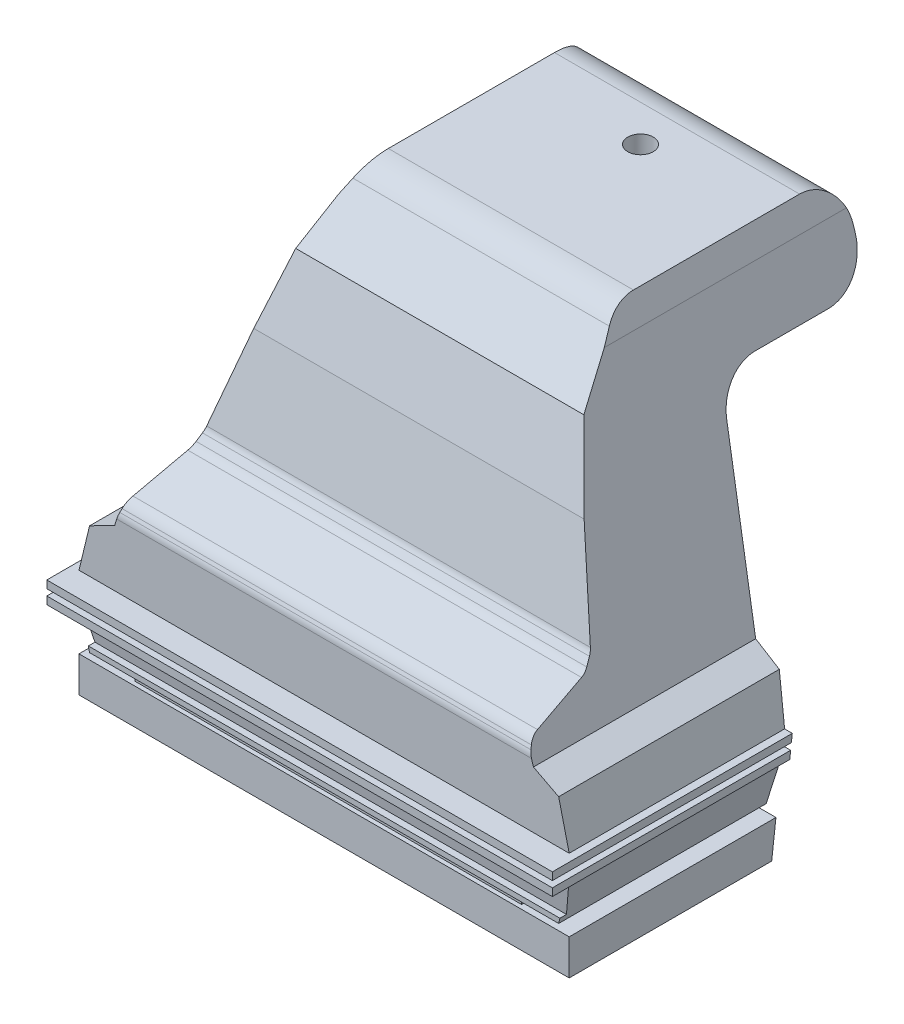
from build123d import *

# Parameters (mm, degrees)
BOSS_EXTRUDE2_DEPTH   = 80
CUT_EXTRUDE6_DEPTH    = 80
FILLET4_R             = 8
FILLET6_R             = 8
BOSS_EXTRUDE3_DEPTH   = 5
CUT_EXTRUDE7_DEPTH    = 53
SKETCH8_W             = 0.862104353
SKETCH8_H             = 1.284661266
CUT_EXTRUDE8_DEPTH    = 53
SKETCH9_R             = 2.6
CUT_EXTRUDE9_DEPTH    = 53
CHAMFER1_SIZE         = 2
CHAMFER1_SIZE2        = 0.352653961
CHAMFER2_SIZE         = 2
CHAMFER2_SIZE2        = 1.125418904
CHAMFER2_PART_2_SIZE  = 2
CHAMFER2_PART_2_SIZE2 = 1.486326178
CHAMFER2_PART_3_SIZE  = 2
CHAMFER2_PART_3_SIZE2 = 12.979996821
FILLET7_R             = 3


with BuildPart() as part:
    # Sketch4 → Boss-Extrude2 (new body)
    with BuildSketch(Plane.XY):
        Polygon((0, 90), (25, 90), (27.110033345, 84.90483075), (42.705570979, 33.625818377), (47.850101428, 30.956311994), (50, 22.038522927), (51.568309777, 22.038522927), (51.568309777, 20.486613591), (50, 20.486613591), (50, 19.211830923), (51.568309777, 19.211830923), (51.568309777, 17.666105021), (50, 17.666105021), (47.850101428, 8.556688769), (39.441409504, 8.556688769), (39.441409504, 7.272027503), (50, 7.272027503), (50, 0), (0, 0), align=None)
    extrude(amount=BOSS_EXTRUDE2_DEPTH)

    # Sketch5 → Cut-Extrude6 (cut)
    with BuildSketch(Plane.ZY):
        Polygon((80, 90), (45.569058945, 90), (57.70788513, 75.886568849), (65.410192712, 42.801872405), (80, 37.57441702), align=None)
        Polygon((30, 72.649548533), (0, 72.649548533), (0, 0), (38.690390773, 0), align=None)
    extrude(amount=-CUT_EXTRUDE6_DEPTH, mode=Mode.SUBTRACT)

    # Fillet4
    fillet4_edges = [part.edges().sort_by_distance(p)[0] for p in [
        (15.418622329, 72.649548533, 0),
        (15.418622329, 72.649548533, 30),
    ]]
    fillet(fillet4_edges, radius=FILLET4_R)

    # Fillet6
    fillet6_edges = [part.edges().sort_by_distance(p)[0] for p in [
        (12.5, 90, 0),
        (12.5, 90, 45.569058945),
    ]]
    fillet(fillet6_edges, radius=FILLET6_R)

    # Sketch6 → Boss-Extrude3 (add)
    with BuildSketch(Plane.XY.offset(80)):
        Polygon((51.568309777, 22.038522927), (50, 22.038522927), (0, 22.038522927), (0, 20.486613591), (50, 20.486613591), (51.568309777, 20.486613591), align=None)
        Polygon((50, 19.211830923), (0, 19.211830923), (0, 17.666105021), (50, 17.666105021), (51.568309777, 17.666105021), (51.568309777, 19.211830923), align=None)
    extrude(amount=BOSS_EXTRUDE3_DEPTH)

    # Sketch7 → Cut-Extrude7 (cut)
    with BuildSketch(Plane.ZY):
        Polygon((80, 17.666105021), (78.657986015, 9.613389648), (80, 9.613389648), align=None)
    extrude(amount=-CUT_EXTRUDE7_DEPTH, mode=Mode.SUBTRACT)

    # Sketch8 → Cut-Extrude8 (cut)
    with BuildSketch(Plane(origin=(39.441409504, 0, 0), x_dir=(0, 0, -1), z_dir=(1, 0, 0))):
        with Locations((-79.568947823, 7.914358136)):
            Rectangle(SKETCH8_W, SKETCH8_H)
    extrude(amount=-CUT_EXTRUDE8_DEPTH, mode=Mode.SUBTRACT)

    # Sketch9 → Cut-Extrude9 (cut)
    with BuildSketch(Plane.XZ.offset(-72.649548533)):
        with Locations((0, 15.44996627)):
            Circle(SKETCH9_R)
    extrude(amount=-CUT_EXTRUDE9_DEPTH, mode=Mode.SUBTRACT)

    # Chamfer1
    chamfer1_edges = [part.edges().sort_by_distance(p)[0] for p in [
        (2.6, 72.649548533, 15.44996627),
    ]]
    chamfer1_side = [part.faces().sort_by_distance(p)[0] for p in [
        (15.75727698, 72.649548533, 15.44996627),
    ]]
    chamfer(chamfer1_edges, length=CHAMFER1_SIZE, length2=CHAMFER1_SIZE2, reference=chamfer1_side[0])

    # Chamfer2
    chamfer2_edges = [part.edges().sort_by_distance(p)[0] for p in [
        (20.75233985, 37.57441702, 80),
    ]]
    chamfer2_side = [part.faces().sort_by_distance(p)[0] for p in [
        (23.38094375, 29.531291641, 80),
    ]]
    chamfer(chamfer2_edges, length=CHAMFER2_SIZE, length2=CHAMFER2_SIZE2, reference=chamfer2_side[0])

    # Chamfer2 part 2
    chamfer2_part_2_edges = [part.edges().sort_by_distance(p)[0] for p in [
        (19.957424217, 42.801872405, 65.410192712),
    ]]
    chamfer2_part_2_side = [part.faces().sort_by_distance(p)[0] for p in [
        (17.56283553, 58.548959268, 61.744180339),
    ]]
    chamfer(chamfer2_part_2_edges, length=CHAMFER2_PART_2_SIZE, length2=CHAMFER2_PART_2_SIZE2, reference=chamfer2_part_2_side[0])

    # Chamfer2 part 3
    chamfer2_part_3_edges = [part.edges().sort_by_distance(p)[0] for p in [
        (14.926383206, 75.886568849, 57.70788513),
    ]]
    chamfer2_part_3_side = [part.faces().sort_by_distance(p)[0] for p in [
        (14.071000693, 81.431316149, 52.938901387),
    ]]
    chamfer(chamfer2_part_3_edges, length=CHAMFER2_PART_3_SIZE, length2=CHAMFER2_PART_3_SIZE2, reference=chamfer2_part_3_side[0])

    # Fillet7
    fillet7_edges = [part.edges().sort_by_distance(p)[0] for p in [
        (19.661214366, 44.749781992, 64.956708159),
        (20.694615521, 37.954018761, 78.940533046),
        (20.033659992, 42.3005373, 66.809417005),
        (21.056470857, 35.57441702, 80),
    ]]
    fillet(fillet7_edges, radius=FILLET7_R)

    # Mirror2: part across plane


with BuildPart() as part_1:
    add(part.part)
    add(part.part.mirror(Plane(origin=(0, 90, 80), x_dir=(0, 0, 1), z_dir=(1, 0, 0))))


solid = part_1.part
